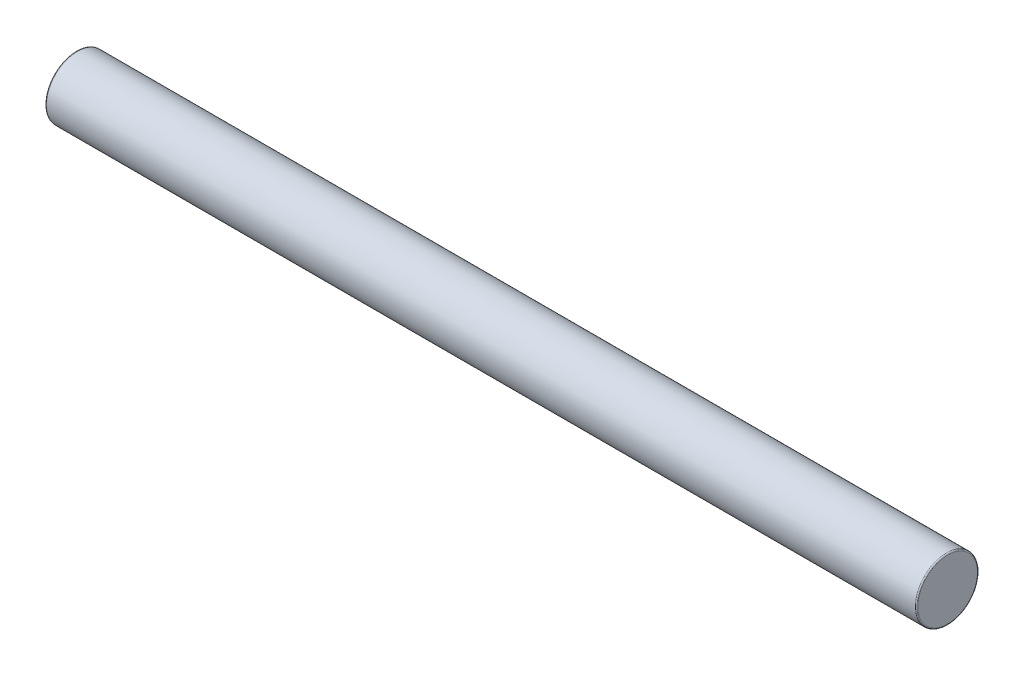
from build123d import *

# Parameters (mm, degrees)
CROQUIS1_R              = 5
SALIENTE_EXTRUIR1_DEPTH = 140
REDONDEO1_R             = 0.2


with BuildPart() as part:
    # Croquis1 → Saliente-Extruir1 (new body)
    with BuildSketch(Plane(origin=(0, 0, 0), x_dir=(0, 0, -1), z_dir=(1, 0, 0))):
        Circle(CROQUIS1_R)
    extrude(amount=SALIENTE_EXTRUIR1_DEPTH)

    # Redondeo1
    redondeo1_edges = [part.edges().sort_by_distance(p)[0] for p in [
        (0, 0, 5),
        (140, 0, 5),
    ]]
    fillet(redondeo1_edges, radius=REDONDEO1_R)


solid = part.part
